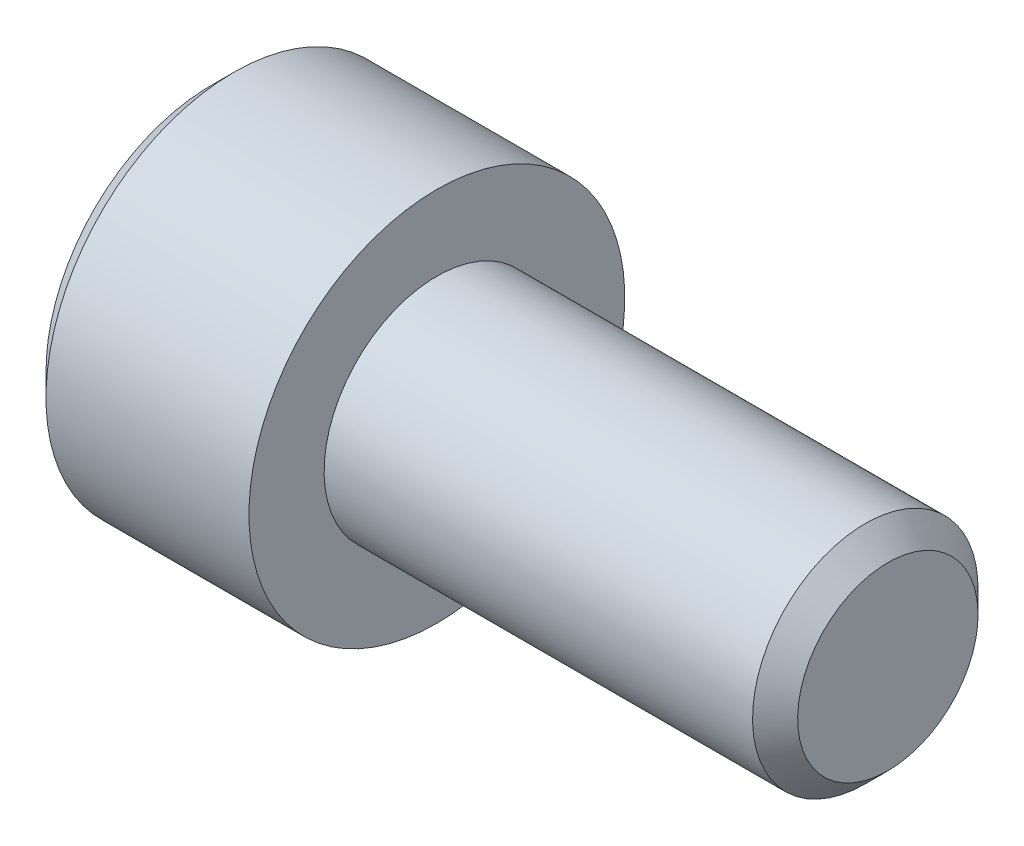
from build123d import *

# Parameters (mm, degrees)
CHAMFER1_SIZE      = 0.6
CUT_EXTRUDE1_DEPTH = 3


with BuildPart() as part:
    # Sketch1 → Revolve1 (revolve)
    with BuildSketch(Plane.XY):
        Polygon((-6, 0), (-6, 4.4), (-5.4, 5), (0, 5), (0, 3), (12, 3), (12, 0), align=None)
    revolve(axis=Axis((12, 0, 0), (-1, 0, 0)))

    # Chamfer1
    chamfer1_edges = [part.edges().sort_by_distance(p)[0] for p in [
        (12, -3, 0),
    ]]
    chamfer(chamfer1_edges, length=CHAMFER1_SIZE)

    # Sketch2 → Cut-Revolve1 (revolve, cut)
    with BuildSketch(Plane.XY):
        Polygon((-6, 0), (-6, 2.5), (-3, 2.5), (-2.330127019, 0), align=None)
    revolve(axis=Axis((-2.330127019, 0, 0), (-1, 0, 0)), mode=Mode.SUBTRACT)

    # Sketch3 → Cut-Extrude1 (cut)
    with BuildSketch(Plane(origin=(-6, 0, 0), x_dir=(0, 0, -1), z_dir=(1, 0, 0))):
        Polygon((-2.5, 1.443375673), (-2.5, -1.443375673), (0, -2.886751346), (2.5, -1.443375673), (2.5, 1.443375673), (0, 2.886751346), align=None)
    extrude(amount=CUT_EXTRUDE1_DEPTH, mode=Mode.SUBTRACT)


solid = part.part
